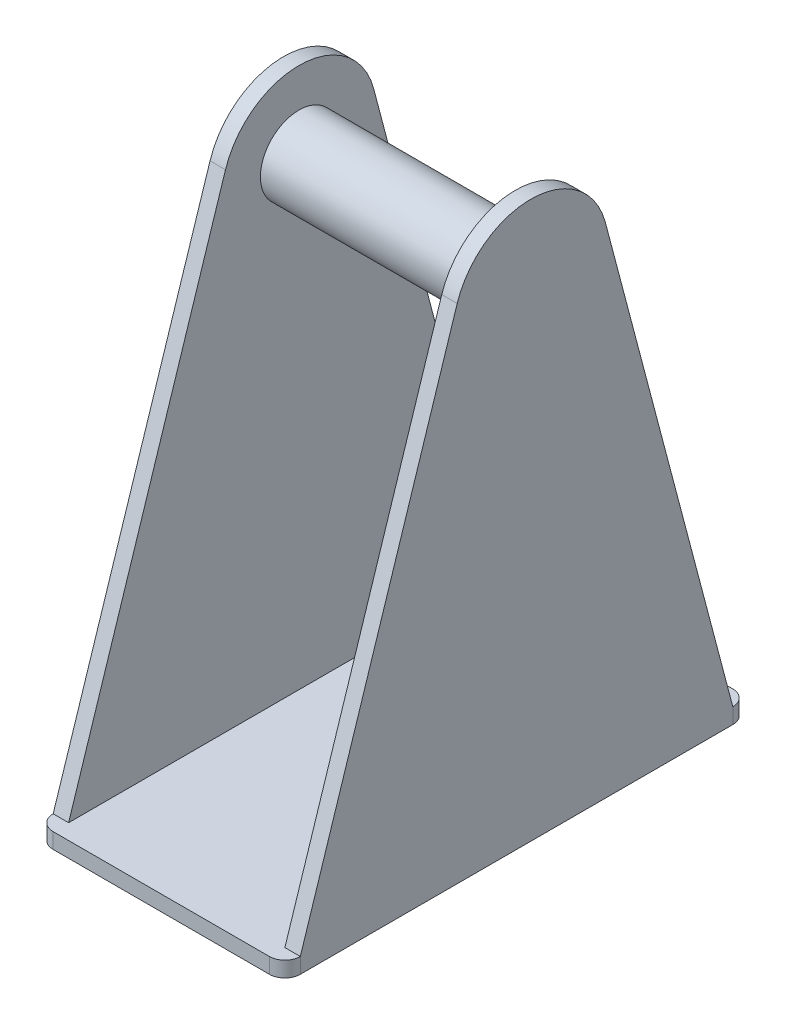
from build123d import *

# Parameters (mm, degrees)
EXTRUDE_1_DEPTH = 1
EXTRUDE_2_DEPTH = 1
EXTRUDE_3_REACH = 17
SKETCH_3_R      = 2.5


with BuildPart() as part:
    # 草图1 → 凸台-拉伸1 (new body)
    with BuildSketch(Plane(origin=(0, 0, 0), x_dir=(1, 0, 0), z_dir=(0, 1, 0))):
        with BuildLine():
            Line((-7, 15), (7, 15))
            ThreePointArc((7, 15), (7.707106781, 14.707106781), (8, 14))
            Line((8, 14), (8, -14))
            ThreePointArc((8, -14), (7.707106781, -14.707106781), (7, -15))
            Line((7, -15), (-7, -15))
            ThreePointArc((-7, -15), (-7.707106781, -14.707106781), (-8, -14))
            Line((-8, -14), (-8, 14))
            ThreePointArc((-8, 14), (-7.707106781, 14.707106781), (-7, 15))
        make_face()
    extrude(amount=EXTRUDE_1_DEPTH)

    # 草图2 → 凸台-拉伸2 (add)
    with BuildSketch(Plane.ZY.offset(8)):
        with BuildLine():
            Line((14, 1), (3.844755362, 32.532743309))
            ThreePointArc((3.844755362, 32.532743309), (-1.048573514, 35.998202631), (-5.749110975, 32.275431702))
            Line((-5.749110975, 32.275431702), (-14, 1))
            Line((-14, 1), (14, 1))
        make_face()
    extrude_2 = extrude(amount=-EXTRUDE_2_DEPTH)

    # 镜向1: 凸台-拉伸2 across plane
    add(extrude_2.mirror(Plane(origin=(0, 0, 0), x_dir=(0, 0, 1), z_dir=(1, 0, 0))))

    # 草图3 → 凸台-拉伸3 (add, up to next)
    with BuildSketch(Plane(origin=(-7, 0, 0), x_dir=(0, 0, -1), z_dir=(1, 0, 0)), mode=Mode.PRIVATE) as extrude_3_sk1:
        with Locations((0.914519578, 31)):
            Circle(SKETCH_3_R)
    extrude_3_tool1 = extrude(extrude_3_sk1.sketch, amount=EXTRUDE_3_REACH, mode=Mode.PRIVATE) - part.part
    add(extrude_3_tool1.solids().sort_by_distance((-7, 31, -0.91452))[0])


solid = part.part
